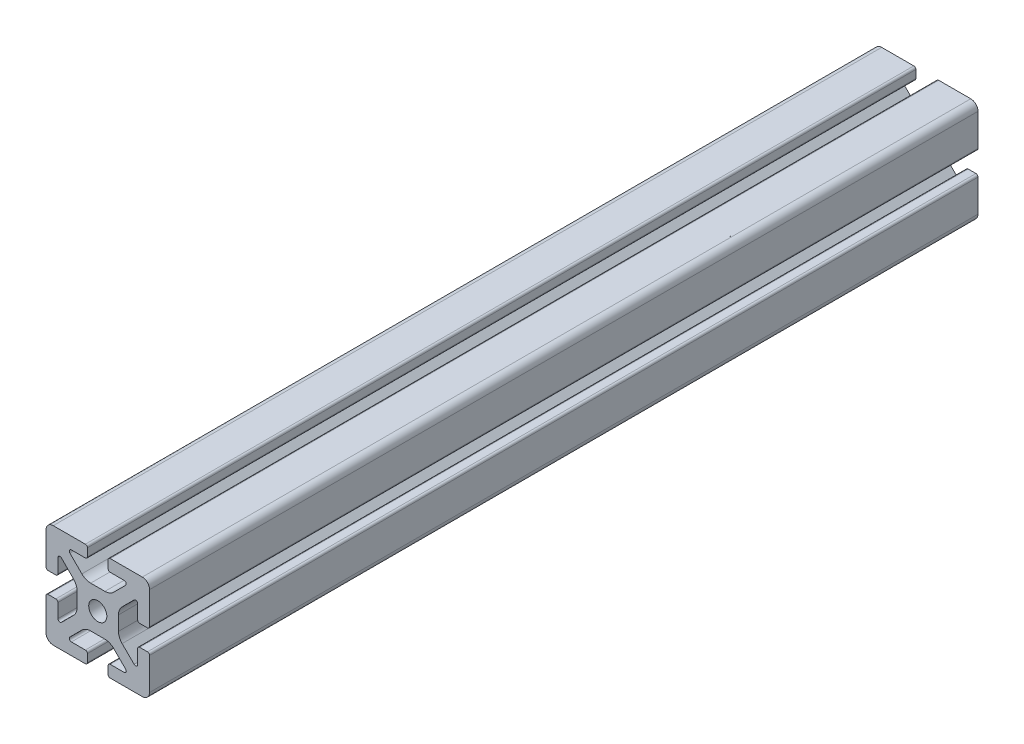
from build123d import *

# Parameters (mm, degrees)
BOSS_EXTRUDE1_DEPTH = 160


with BuildPart() as part:
    # Sketch4 → Boss-Extrude1 (new body, symmetric)
    with BuildSketch(Plane.XY):
        with BuildLine():
            Line((4.8, -20), (17.2, -20))
            ThreePointArc((17.2, -20), (19.179898987, -19.179898987), (20, -17.2))
            Line((20, -17.2), (20, -4.8))
            ThreePointArc((20, -4.8), (19.765685425, -4.234314575), (19.2, -4))
            Line((19.2, -4), (16.190663761, -4))
            ThreePointArc((16.190663761, -4), (15.624978336, -4.234314575), (15.390663761, -4.8))
            Line((15.390663761, -4.8), (15.390663761, -10.2))
            ThreePointArc((15.390663761, -10.2), (14.896810507, -10.939103626), (14.024978336, -10.765685425))
            Line((14.024978336, -10.765685425), (9.40588745, -6.146594539))
            ThreePointArc((9.40588745, -6.146594539), (8.365378244, -4.589362465), (8, -2.752481989))
            Line((8, -2.752481989), (8, 0))
            Line((8, 0), (3.5, 0))
            ThreePointArc((3.5, 0), (2.474873734, -2.474873734), (0, -3.5))
            Line((0, -3.5), (0, -8))
            Line((0, -8), (2.752481989, -8))
            ThreePointArc((2.752481989, -8), (4.589362465, -8.365378244), (6.146594539, -9.40588745))
            Line((6.146594539, -9.40588745), (10.765685425, -14.024978336))
            ThreePointArc((10.765685425, -14.024978336), (10.939103626, -14.896810507), (10.2, -15.390663761))
            Line((10.2, -15.390663761), (4.8, -15.390663761))
            ThreePointArc((4.8, -15.390663761), (4.234314575, -15.624978336), (4, -16.190663761))
            Line((4, -16.190663761), (4, -19.2))
            ThreePointArc((4, -19.2), (4.234314575, -19.765685425), (4.8, -20))
        make_face()
    extrude(amount=BOSS_EXTRUDE1_DEPTH, both=True)

    # Mirror1: part across plane


with BuildPart() as part_1:
    add(part.part)
    add(part.part.mirror(Plane(origin=(0, 0, 0), x_dir=(0, 0, 1), z_dir=(1, 0, 0))))

    # Mirror2: part across plane


with BuildPart() as part_2:
    add(part_1.part)
    add(part_1.part.mirror(Plane.ZX))


solid = part_2.part
